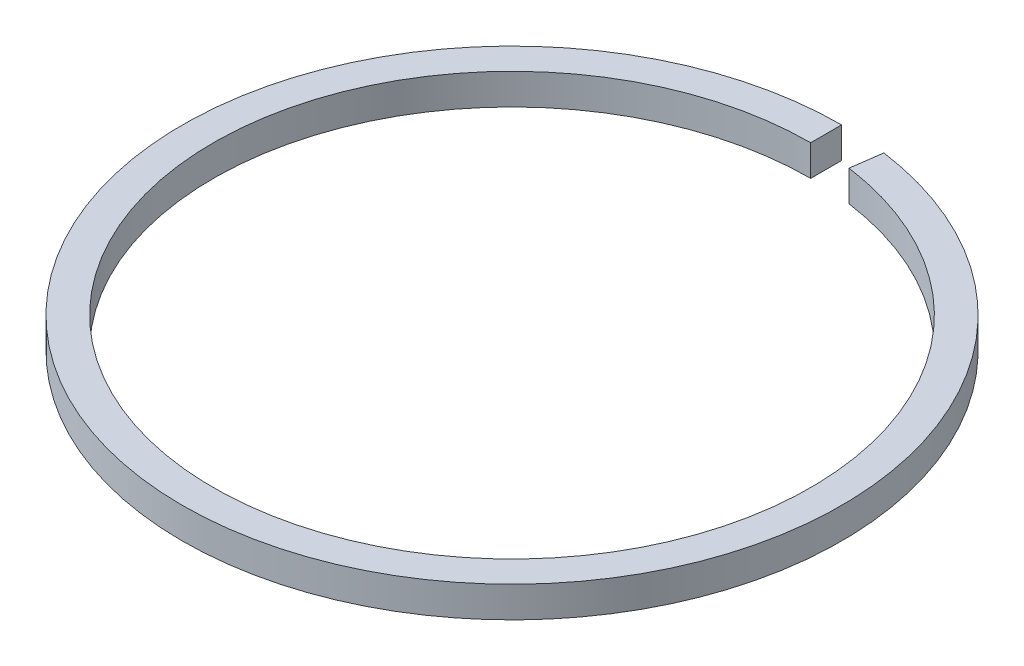
from build123d import *

# Parameters (mm, degrees)
SKETCH1_W = 0.75
SKETCH1_H = 0.75


with BuildPart() as part:
    # Sweep1: sweep along a path in Sketch2
    with BuildLine(Plane(origin=(0, 0, 0), x_dir=(1, 0, 0), z_dir=(0, 1, 0))) as sweep1_path:
        ThreePointArc((0, -0.375), (-0.50119907, -14.857655079), (1, -0.444296692))
    # Sketch1 → Sweep1 (sweep)
    with BuildSketch(Plane(origin=(0, 0, 0), x_dir=(0, 0, -1), z_dir=(1, 0, 0))):
        Rectangle(SKETCH1_W, SKETCH1_H)
    sweep(path=sweep1_path.line)


solid = part.part
